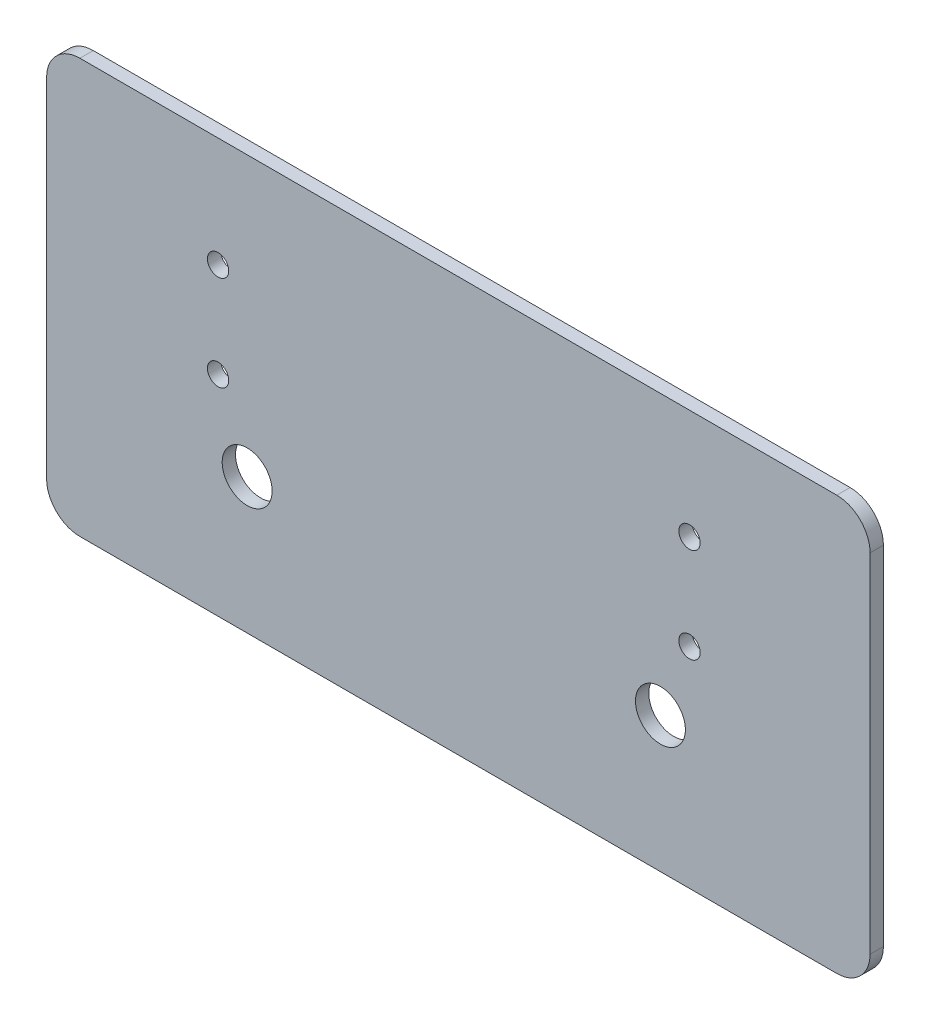
from build123d import *

# Parameters (mm, degrees)
BOSS_EXTRUDE1_DEPTH  = 4
M6_CLEARANCE_HOLE1_D = 6.4
SKETCH5_R            = 7.5
CUT_EXTRUDE1_DEPTH   = 40.678061403


with BuildPart() as part:
    # Sketch1 → Boss-Extrude1 (new body)
    with BuildSketch(Plane.XY):
        with BuildLine():
            Line((98.386811049, -384.8287802), (-128.910956341, -384.8287802))
            ThreePointArc((-128.910956341, -384.8287802), (-135.982024153, -381.899848012), (-138.910956341, -374.8287802))
            Line((-138.910956341, -374.8287802), (-138.910956341, -270.434125192))
            ThreePointArc((-138.910956341, -270.434125192), (-135.982024153, -263.36305738), (-128.910956341, -260.434125192))
            Line((-128.910956341, -260.434125192), (98.386811049, -260.434125192))
            ThreePointArc((98.386811049, -260.434125192), (105.457878861, -263.36305738), (108.386811049, -270.434125192))
            Line((108.386811049, -270.434125192), (108.386811049, -374.8287802))
            ThreePointArc((108.386811049, -374.8287802), (105.457878861, -381.899848012), (98.386811049, -384.8287802))
        make_face()
    extrude(amount=BOSS_EXTRUDE1_DEPTH)

    # M6 Clearance Hole1 (through all)
    with Locations(Plane.XY.offset(4)):
        with Locations((54.16270611, -293.415681156), (54.16270611, -321.915681156), (45.426427008, -344.165502047), (-78.681014788, -344.165502047), (-87.41729389, -321.915681156), (-87.41729389, -293.415681156)):
            Hole(M6_CLEARANCE_HOLE1_D / 2)

    # Sketch5 → Cut-Extrude1 (cut)
    with BuildSketch(Plane.XY.offset(4)):
        with Locations((-78.681014788, -344.165502047)):
            Circle(SKETCH5_R)
        with Locations((45.426427008, -344.165502047)):
            Circle(SKETCH5_R)
    extrude(amount=-CUT_EXTRUDE1_DEPTH, mode=Mode.SUBTRACT)


solid = part.part
